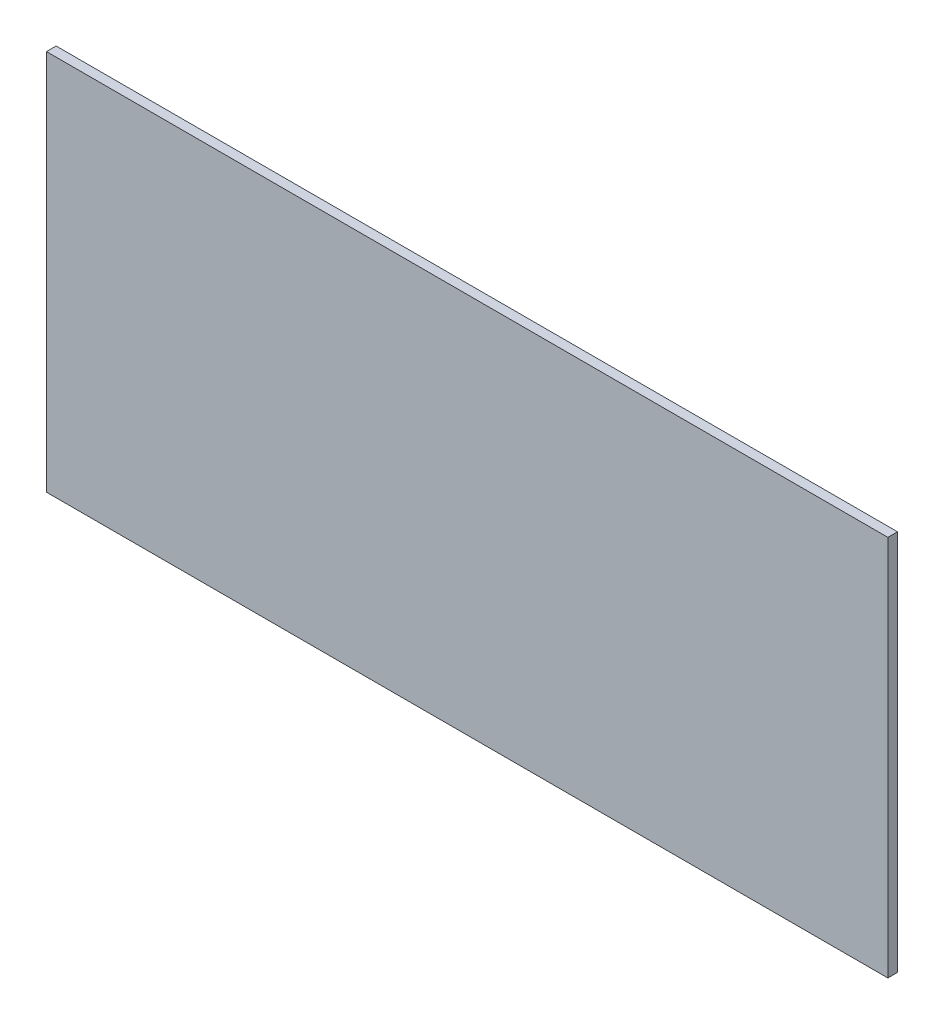
from build123d import *

# Parameters (mm, degrees)
SKETCH1_W           = 261.28
SKETCH1_H           = 118.5
BOSS_EXTRUDE1_DEPTH = 3


with BuildPart() as part:
    # Sketch1 → Boss-Extrude1 (new body)
    with BuildSketch(Plane.XY):
        Rectangle(SKETCH1_W, SKETCH1_H)
    extrude(amount=BOSS_EXTRUDE1_DEPTH)


solid = part.part
